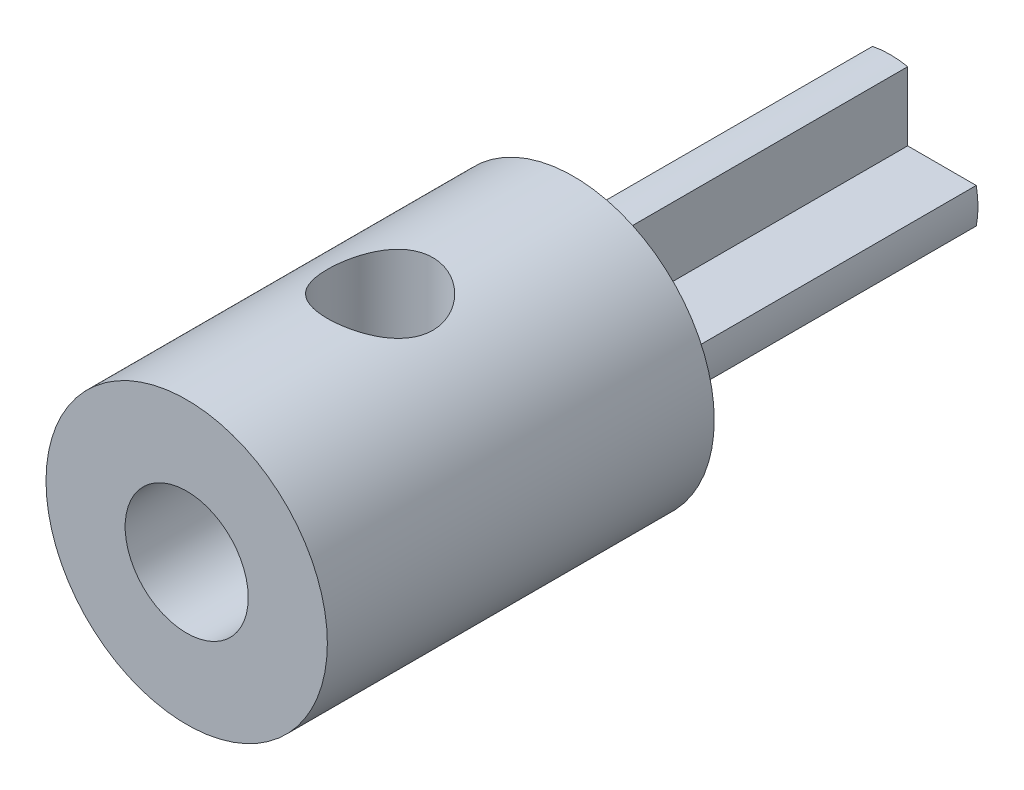
from build123d import *

# Parameters (mm, degrees)
SKETCH1_R               = 4
SKETCH1_R_2             = 1.75
BOSS_EXTRUDE1_DEPTH     = 10
SKETCH2_W               = 1
SKETCH2_H               = 1
BOSS_EXTRUDE2_DEPTH     = 10
SKETCH3_R               = 4
BOSS_EXTRUDE3_DEPTH     = 1
SKETCH4_R               = 1.5
CUT_EXTRUDE1_DEPTH      = 5
CUT_EXTRUDE1_DEPTH_BACK = 5


with BuildPart() as part:
    # Sketch1 → Boss-Extrude1 (new body)
    with BuildSketch(Plane.XY):
        Circle(SKETCH1_R)
        Circle(SKETCH1_R_2, mode=Mode.SUBTRACT)
    extrude(amount=BOSS_EXTRUDE1_DEPTH)

    # Sketch2 → Boss-Extrude2 (add)
    with BuildSketch(Plane(origin=(0, 0, 0), x_dir=(-1, 0, 0), z_dir=(0, 0, -1))):
        with BuildLine():
            ThreePointArc((0.5, 1.677050983), (0, 1.75), (-0.5, 1.677050983))
            Line((-0.5, 1.677050983), (-0.5, 0.5))
            Line((-0.5, 0.5), (0.5, 0.5))
            Line((0.5, 0.5), (0.5, 1.677050983))
        make_face()
        with BuildLine():
            ThreePointArc((0.5, 2.449489743), (0, 2.5), (-0.5, 2.449489743))
            Line((-0.5, 2.449489743), (-0.5, 1.677050983))
            ThreePointArc((-0.5, 1.677050983), (0, 1.75), (0.5, 1.677050983))
            Line((0.5, 1.677050983), (0.5, 2.449489743))
        make_face()
        with BuildLine():
            Line((-0.5, -1.677050983), (-0.5, -2.449489743))
            ThreePointArc((-0.5, -2.449489743), (0, -2.5), (0.5, -2.449489743))
            Line((0.5, -2.449489743), (0.5, -1.677050983))
            ThreePointArc((0.5, -1.677050983), (0, -1.75), (-0.5, -1.677050983))
        make_face()
        with BuildLine():
            Line((-0.5, -0.5), (-0.5, 0.5))
            Line((-0.5, 0.5), (-1.677050983, 0.5))
            ThreePointArc((-1.677050983, 0.5), (-1.75, 0), (-1.677050983, -0.5))
            Line((-1.677050983, -0.5), (-0.5, -0.5))
        make_face()
        with BuildLine():
            Line((-1.677050983, 0.5), (-2.449489743, 0.5))
            ThreePointArc((-2.449489743, 0.5), (-2.5, 0), (-2.449489743, -0.5))
            Line((-2.449489743, -0.5), (-1.677050983, -0.5))
            ThreePointArc((-1.677050983, -0.5), (-1.75, 0), (-1.677050983, 0.5))
        make_face()
        with BuildLine():
            ThreePointArc((2.5, 0), (2.487340383, 0.251272405), (2.449489743, 0.5))
            Line((2.449489743, 0.5), (1.677050983, 0.5))
            ThreePointArc((1.677050983, 0.5), (1.731666715, 0.252646769), (1.75, 0))
            ThreePointArc((1.75, 0), (1.731666715, -0.252646769), (1.677050983, -0.5))
            Line((1.677050983, -0.5), (2.449489743, -0.5))
            ThreePointArc((2.449489743, -0.5), (2.487340383, -0.251272405), (2.5, 0))
        make_face()
        with BuildLine():
            Line((0.5, -0.5), (-0.5, -0.5))
            Line((-0.5, -0.5), (-0.5, -1.677050983))
            ThreePointArc((-0.5, -1.677050983), (0, -1.75), (0.5, -1.677050983))
            Line((0.5, -1.677050983), (0.5, -0.5))
        make_face()
        Rectangle(SKETCH2_W, SKETCH2_H)
        with BuildLine():
            Line((1.677050983, 0.5), (0.5, 0.5))
            Line((0.5, 0.5), (0.5, -0.5))
            Line((0.5, -0.5), (1.677050983, -0.5))
            ThreePointArc((1.677050983, -0.5), (1.731666715, -0.252646769), (1.75, 0))
            ThreePointArc((1.75, 0), (1.731666715, 0.252646769), (1.677050983, 0.5))
        make_face()
    extrude(amount=BOSS_EXTRUDE2_DEPTH)

    # Sketch3 → Boss-Extrude3 (add)
    with BuildSketch(Plane(origin=(0, 0, 0), x_dir=(-1, 0, 0), z_dir=(0, 0, -1))):
        Circle(SKETCH3_R)
    extrude(amount=BOSS_EXTRUDE3_DEPTH)

    # Sketch4 → Cut-Extrude1 (cut, two sides)
    with BuildSketch(Plane(origin=(0, 0, 0), x_dir=(1, 0, 0), z_dir=(0, 1, 0))) as cut_extrude1_sk:
        with Locations((0, -4.5)):
            Circle(SKETCH4_R)
    extrude(amount=CUT_EXTRUDE1_DEPTH, mode=Mode.SUBTRACT)
    extrude(cut_extrude1_sk.sketch, amount=-CUT_EXTRUDE1_DEPTH_BACK, mode=Mode.SUBTRACT)


solid = part.part
